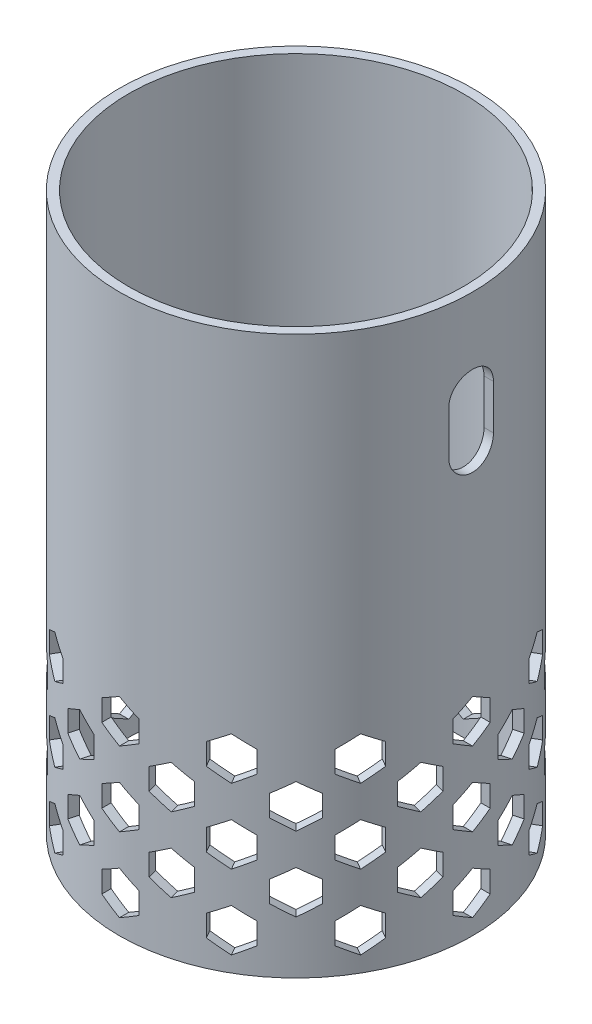
from build123d import *

# Parameters (mm, degrees)
SKETCH1_R               = 47.5
SKETCH1_R_2             = 45
BOSS_EXTRUDE1_DEPTH     = 150
CUT_EXTRUDE1_DEPTH      = 150
CUT_EXTRUDE2_DEPTH      = 48.5000001
CIRPATTERN1_COUNT       = 12
CUT_EXTRUDE3_DEPTH      = 130
CIRPATTERN2_COUNT       = 12
LPATTERN2_COUNT         = 2
LPATTERN2_PITCH         = 20
LPATTERN2_COPY_1_DEPTH  = 130
LPATTERN2_COPY_2_DEPTH  = 130
LPATTERN2_COPY_3_DEPTH  = 130
LPATTERN2_COPY_4_DEPTH  = 130
LPATTERN2_COPY_5_DEPTH  = 130
LPATTERN2_COPY_6_DEPTH  = 130
LPATTERN2_COPY_7_DEPTH  = 130
LPATTERN2_COPY_8_DEPTH  = 130
LPATTERN2_COPY_9_DEPTH  = 130
LPATTERN2_COPY_10_DEPTH = 130
LPATTERN2_COPY_11_DEPTH = 130
LPATTERN3_COUNT         = 3
LPATTERN3_PITCH         = 20
LPATTERN3_COPY_1_DEPTH  = 48.5000001
LPATTERN3_COPY_2_DEPTH  = 48.5000001
LPATTERN3_COPY_3_DEPTH  = 48.5000001
LPATTERN3_COPY_4_DEPTH  = 48.5000001
LPATTERN3_COPY_5_DEPTH  = 48.5000001
LPATTERN3_COPY_6_DEPTH  = 48.5000001
LPATTERN3_COPY_7_DEPTH  = 48.5000001
LPATTERN3_COPY_8_DEPTH  = 48.5000001
LPATTERN3_COPY_9_DEPTH  = 48.5000001
LPATTERN3_COPY_10_DEPTH = 48.5000001
LPATTERN3_COPY_11_DEPTH = 48.5000001
LPATTERN3_COPY_12_DEPTH = 48.5000001
LPATTERN3_COPY_13_DEPTH = 48.5000001
LPATTERN3_COPY_14_DEPTH = 48.5000001
LPATTERN3_COPY_15_DEPTH = 48.5000001
LPATTERN3_COPY_16_DEPTH = 48.5000001
LPATTERN3_COPY_17_DEPTH = 48.5000001
LPATTERN3_COPY_18_DEPTH = 48.5000001
LPATTERN3_COPY_19_DEPTH = 48.5000001
LPATTERN3_COPY_20_DEPTH = 48.5000001
LPATTERN3_COPY_21_DEPTH = 48.5000001
LPATTERN3_COPY_22_DEPTH = 48.5000001


with BuildPart() as part:
    # Sketch1 → Boss-Extrude1 (new body)
    with BuildSketch(Plane(origin=(0, 0, 0), x_dir=(1, 0, 0), z_dir=(0, 1, 0))):
        Circle(SKETCH1_R)
        Circle(SKETCH1_R_2, mode=Mode.SUBTRACT)
    extrude(amount=BOSS_EXTRUDE1_DEPTH)

    # Sketch2 → Cut-Extrude1 (cut)
    with BuildSketch(Plane(origin=(0, 0, 0), x_dir=(0, 0, -1), z_dir=(1, 0, 0))):
        with BuildLine():
            Line((6, 126), (6, 114))
            ThreePointArc((6, 114), (0, 108), (-6, 114))
            Line((-6, 114), (-6, 126))
            ThreePointArc((-6, 126), (0, 132), (6, 126))
        make_face()
    extrude(amount=CUT_EXTRUDE1_DEPTH, mode=Mode.SUBTRACT)

    # Sketch3 → Cut-Extrude2 (cut, symmetric)
    with BuildSketch(Plane(origin=(0, 0, 0), x_dir=(0, 0, -1), z_dir=(1, 0, 0))):
        Polygon((0, 4.226497308), (5, 7.113248654), (5, 12.886751346), (0, 15.773502692), (-5, 12.886751346), (-5, 7.113248654), align=None)
    cut_extrude2 = extrude(amount=CUT_EXTRUDE2_DEPTH, both=True, mode=Mode.SUBTRACT)

    # CirPattern1: Cut-Extrude2 ×12 about axis
    cirpattern1_axis = Axis((0, 0, 0), (0, 1, 0))
    for i in range(1, CIRPATTERN1_COUNT):
        add(cut_extrude2.rotate(cirpattern1_axis, i * 360 / CIRPATTERN1_COUNT), mode=Mode.SUBTRACT)

    # Sketch5 → Cut-Extrude3 (cut)
    with BuildSketch(Plane(origin=(0, 0, 0), x_dir=(0, 1, 0), z_dir=(-0.965925826, 0, 0.258819045))):
        Polygon((14.226497308, 0), (17.113248654, -5), (22.886751346, -5), (25.773502692, 0), (22.886751346, 5), (17.113248654, 5), align=None)
    cut_extrude3 = extrude(amount=-CUT_EXTRUDE3_DEPTH, mode=Mode.SUBTRACT)

    # CirPattern2: Cut-Extrude3 ×12 about axis
    cirpattern2_axis = Axis((0, 0, 0), (0, 1, 0))
    for i in range(1, CIRPATTERN2_COUNT):
        add(cut_extrude3.rotate(cirpattern2_axis, i * 360 / CIRPATTERN2_COUNT), mode=Mode.SUBTRACT)

    # LPattern2: Cut-Extrude3 ×2
    with Locations(*[(0, i * LPATTERN2_PITCH, 0) for i in range(1, LPATTERN2_COUNT)]):
        add(cut_extrude3, mode=Mode.SUBTRACT)

    # LPattern2 copy 1 sketch → LPattern2 copy 1 (cut)
    with BuildSketch(Plane(origin=(0, 20, 0), x_dir=(0, 1, 0), z_dir=(-0.707106781, 0, 0.707106781))):
        Polygon((14.226497308, 0), (17.113248654, -5), (22.886751346, -5), (25.773502692, 0), (22.886751346, 5), (17.113248654, 5), align=None)
    extrude(amount=-LPATTERN2_COPY_1_DEPTH, mode=Mode.SUBTRACT)

    # LPattern2 copy 2 sketch → LPattern2 copy 2 (cut)
    with BuildSketch(Plane(origin=(0, 20, 0), x_dir=(0, 1, 0), z_dir=(-0.258819045, 0, 0.965925826))):
        Polygon((14.226497308, 0), (17.113248654, -5), (22.886751346, -5), (25.773502692, 0), (22.886751346, 5), (17.113248654, 5), align=None)
    extrude(amount=-LPATTERN2_COPY_2_DEPTH, mode=Mode.SUBTRACT)

    # LPattern2 copy 3 sketch → LPattern2 copy 3 (cut)
    with BuildSketch(Plane(origin=(0, 20, 0), x_dir=(0, 1, 0), z_dir=(0.258819045, 0, 0.965925826))):
        Polygon((14.226497308, 0), (17.113248654, -5), (22.886751346, -5), (25.773502692, 0), (22.886751346, 5), (17.113248654, 5), align=None)
    extrude(amount=-LPATTERN2_COPY_3_DEPTH, mode=Mode.SUBTRACT)

    # LPattern2 copy 4 sketch → LPattern2 copy 4 (cut)
    with BuildSketch(Plane(origin=(0, 20, 0), x_dir=(0, 1, 0), z_dir=(0.707106781, 0, 0.707106781))):
        Polygon((14.226497308, 0), (17.113248654, -5), (22.886751346, -5), (25.773502692, 0), (22.886751346, 5), (17.113248654, 5), align=None)
    extrude(amount=-LPATTERN2_COPY_4_DEPTH, mode=Mode.SUBTRACT)

    # LPattern2 copy 5 sketch → LPattern2 copy 5 (cut)
    with BuildSketch(Plane(origin=(0, 20, 0), x_dir=(0, 1, 0), z_dir=(0.965925826, 0, 0.258819045))):
        Polygon((14.226497308, 0), (17.113248654, -5), (22.886751346, -5), (25.773502692, 0), (22.886751346, 5), (17.113248654, 5), align=None)
    extrude(amount=-LPATTERN2_COPY_5_DEPTH, mode=Mode.SUBTRACT)

    # LPattern2 copy 6 sketch → LPattern2 copy 6 (cut)
    with BuildSketch(Plane(origin=(0, 20, 0), x_dir=(0, 1, 0), z_dir=(0.965925826, 0, -0.258819045))):
        Polygon((14.226497308, 0), (17.113248654, -5), (22.886751346, -5), (25.773502692, 0), (22.886751346, 5), (17.113248654, 5), align=None)
    extrude(amount=-LPATTERN2_COPY_6_DEPTH, mode=Mode.SUBTRACT)

    # LPattern2 copy 7 sketch → LPattern2 copy 7 (cut)
    with BuildSketch(Plane(origin=(0, 20, 0), x_dir=(0, 1, 0), z_dir=(0.707106781, 0, -0.707106781))):
        Polygon((14.226497308, 0), (17.113248654, -5), (22.886751346, -5), (25.773502692, 0), (22.886751346, 5), (17.113248654, 5), align=None)
    extrude(amount=-LPATTERN2_COPY_7_DEPTH, mode=Mode.SUBTRACT)

    # LPattern2 copy 8 sketch → LPattern2 copy 8 (cut)
    with BuildSketch(Plane(origin=(0, 20, 0), x_dir=(0, 1, 0), z_dir=(0.258819045, 0, -0.965925826))):
        Polygon((14.226497308, 0), (17.113248654, -5), (22.886751346, -5), (25.773502692, 0), (22.886751346, 5), (17.113248654, 5), align=None)
    extrude(amount=-LPATTERN2_COPY_8_DEPTH, mode=Mode.SUBTRACT)

    # LPattern2 copy 9 sketch → LPattern2 copy 9 (cut)
    with BuildSketch(Plane(origin=(0, 20, 0), x_dir=(0, 1, 0), z_dir=(-0.258819045, 0, -0.965925826))):
        Polygon((14.226497308, 0), (17.113248654, -5), (22.886751346, -5), (25.773502692, 0), (22.886751346, 5), (17.113248654, 5), align=None)
    extrude(amount=-LPATTERN2_COPY_9_DEPTH, mode=Mode.SUBTRACT)

    # LPattern2 copy 10 sketch → LPattern2 copy 10 (cut)
    with BuildSketch(Plane(origin=(0, 20, 0), x_dir=(0, 1, 0), z_dir=(-0.707106781, 0, -0.707106781))):
        Polygon((14.226497308, 0), (17.113248654, -5), (22.886751346, -5), (25.773502692, 0), (22.886751346, 5), (17.113248654, 5), align=None)
    extrude(amount=-LPATTERN2_COPY_10_DEPTH, mode=Mode.SUBTRACT)

    # LPattern2 copy 11 sketch → LPattern2 copy 11 (cut)
    with BuildSketch(Plane(origin=(0, 20, 0), x_dir=(0, 1, 0), z_dir=(-0.965925826, 0, -0.258819045))):
        Polygon((14.226497308, 0), (17.113248654, -5), (22.886751346, -5), (25.773502692, 0), (22.886751346, 5), (17.113248654, 5), align=None)
    extrude(amount=-LPATTERN2_COPY_11_DEPTH, mode=Mode.SUBTRACT)

    # LPattern3: Cut-Extrude2 ×3
    with Locations(*[(0, i * LPATTERN3_PITCH, 0) for i in range(1, LPATTERN3_COUNT)]):
        add(cut_extrude2, mode=Mode.SUBTRACT)

    # LPattern3 copy 1 sketch → LPattern3 copy 1 (cut, symmetric)
    with BuildSketch(Plane(origin=(0, 20, 0), x_dir=(-0.5, 0, -0.866025404), z_dir=(0.866025404, 0, -0.5))):
        Polygon((0, 4.226497308), (5, 7.113248654), (5, 12.886751346), (0, 15.773502692), (-5, 12.886751346), (-5, 7.113248654), align=None)
    extrude(amount=LPATTERN3_COPY_1_DEPTH, both=True, mode=Mode.SUBTRACT)

    # LPattern3 copy 2 sketch → LPattern3 copy 2 (cut, symmetric)
    with BuildSketch(Plane(origin=(0, 40, 0), x_dir=(-0.5, 0, -0.866025404), z_dir=(0.866025404, 0, -0.5))):
        Polygon((0, 4.226497308), (5, 7.113248654), (5, 12.886751346), (0, 15.773502692), (-5, 12.886751346), (-5, 7.113248654), align=None)
    extrude(amount=LPATTERN3_COPY_2_DEPTH, both=True, mode=Mode.SUBTRACT)

    # LPattern3 copy 3 sketch → LPattern3 copy 3 (cut, symmetric)
    with BuildSketch(Plane(origin=(0, 20, 0), x_dir=(-0.866025404, 0, -0.5), z_dir=(0.5, 0, -0.866025404))):
        Polygon((0, 4.226497308), (5, 7.113248654), (5, 12.886751346), (0, 15.773502692), (-5, 12.886751346), (-5, 7.113248654), align=None)
    extrude(amount=LPATTERN3_COPY_3_DEPTH, both=True, mode=Mode.SUBTRACT)

    # LPattern3 copy 4 sketch → LPattern3 copy 4 (cut, symmetric)
    with BuildSketch(Plane(origin=(0, 40, 0), x_dir=(-0.866025404, 0, -0.5), z_dir=(0.5, 0, -0.866025404))):
        Polygon((0, 4.226497308), (5, 7.113248654), (5, 12.886751346), (0, 15.773502692), (-5, 12.886751346), (-5, 7.113248654), align=None)
    extrude(amount=LPATTERN3_COPY_4_DEPTH, both=True, mode=Mode.SUBTRACT)

    # LPattern3 copy 5 sketch → LPattern3 copy 5 (cut, symmetric)
    with BuildSketch(Plane(origin=(0, 20, 0), x_dir=(-1, 0, 0), z_dir=(0, 0, -1))):
        Polygon((0, 4.226497308), (5, 7.113248654), (5, 12.886751346), (0, 15.773502692), (-5, 12.886751346), (-5, 7.113248654), align=None)
    extrude(amount=LPATTERN3_COPY_5_DEPTH, both=True, mode=Mode.SUBTRACT)

    # LPattern3 copy 6 sketch → LPattern3 copy 6 (cut, symmetric)
    with BuildSketch(Plane(origin=(0, 40, 0), x_dir=(-1, 0, 0), z_dir=(0, 0, -1))):
        Polygon((0, 4.226497308), (5, 7.113248654), (5, 12.886751346), (0, 15.773502692), (-5, 12.886751346), (-5, 7.113248654), align=None)
    extrude(amount=LPATTERN3_COPY_6_DEPTH, both=True, mode=Mode.SUBTRACT)

    # LPattern3 copy 7 sketch → LPattern3 copy 7 (cut, symmetric)
    with BuildSketch(Plane(origin=(0, 20, 0), x_dir=(-0.866025404, 0, 0.5), z_dir=(-0.5, 0, -0.866025404))):
        Polygon((0, 4.226497308), (5, 7.113248654), (5, 12.886751346), (0, 15.773502692), (-5, 12.886751346), (-5, 7.113248654), align=None)
    extrude(amount=LPATTERN3_COPY_7_DEPTH, both=True, mode=Mode.SUBTRACT)

    # LPattern3 copy 8 sketch → LPattern3 copy 8 (cut, symmetric)
    with BuildSketch(Plane(origin=(0, 40, 0), x_dir=(-0.866025404, 0, 0.5), z_dir=(-0.5, 0, -0.866025404))):
        Polygon((0, 4.226497308), (5, 7.113248654), (5, 12.886751346), (0, 15.773502692), (-5, 12.886751346), (-5, 7.113248654), align=None)
    extrude(amount=LPATTERN3_COPY_8_DEPTH, both=True, mode=Mode.SUBTRACT)

    # LPattern3 copy 9 sketch → LPattern3 copy 9 (cut, symmetric)
    with BuildSketch(Plane(origin=(0, 20, 0), x_dir=(-0.5, 0, 0.866025404), z_dir=(-0.866025404, 0, -0.5))):
        Polygon((0, 4.226497308), (5, 7.113248654), (5, 12.886751346), (0, 15.773502692), (-5, 12.886751346), (-5, 7.113248654), align=None)
    extrude(amount=LPATTERN3_COPY_9_DEPTH, both=True, mode=Mode.SUBTRACT)

    # LPattern3 copy 10 sketch → LPattern3 copy 10 (cut, symmetric)
    with BuildSketch(Plane(origin=(0, 40, 0), x_dir=(-0.5, 0, 0.866025404), z_dir=(-0.866025404, 0, -0.5))):
        Polygon((0, 4.226497308), (5, 7.113248654), (5, 12.886751346), (0, 15.773502692), (-5, 12.886751346), (-5, 7.113248654), align=None)
    extrude(amount=LPATTERN3_COPY_10_DEPTH, both=True, mode=Mode.SUBTRACT)

    # LPattern3 copy 11 sketch → LPattern3 copy 11 (cut, symmetric)
    with BuildSketch(Plane(origin=(0, 20, 0), x_dir=(0, 0, 1), z_dir=(-1, 0, 0))):
        Polygon((0, 4.226497308), (5, 7.113248654), (5, 12.886751346), (0, 15.773502692), (-5, 12.886751346), (-5, 7.113248654), align=None)
    extrude(amount=LPATTERN3_COPY_11_DEPTH, both=True, mode=Mode.SUBTRACT)

    # LPattern3 copy 12 sketch → LPattern3 copy 12 (cut, symmetric)
    with BuildSketch(Plane(origin=(0, 40, 0), x_dir=(0, 0, 1), z_dir=(-1, 0, 0))):
        Polygon((0, 4.226497308), (5, 7.113248654), (5, 12.886751346), (0, 15.773502692), (-5, 12.886751346), (-5, 7.113248654), align=None)
    extrude(amount=LPATTERN3_COPY_12_DEPTH, both=True, mode=Mode.SUBTRACT)

    # LPattern3 copy 13 sketch → LPattern3 copy 13 (cut, symmetric)
    with BuildSketch(Plane(origin=(0, 20, 0), x_dir=(0.5, 0, 0.866025404), z_dir=(-0.866025404, 0, 0.5))):
        Polygon((0, 4.226497308), (5, 7.113248654), (5, 12.886751346), (0, 15.773502692), (-5, 12.886751346), (-5, 7.113248654), align=None)
    extrude(amount=LPATTERN3_COPY_13_DEPTH, both=True, mode=Mode.SUBTRACT)

    # LPattern3 copy 14 sketch → LPattern3 copy 14 (cut, symmetric)
    with BuildSketch(Plane(origin=(0, 40, 0), x_dir=(0.5, 0, 0.866025404), z_dir=(-0.866025404, 0, 0.5))):
        Polygon((0, 4.226497308), (5, 7.113248654), (5, 12.886751346), (0, 15.773502692), (-5, 12.886751346), (-5, 7.113248654), align=None)
    extrude(amount=LPATTERN3_COPY_14_DEPTH, both=True, mode=Mode.SUBTRACT)

    # LPattern3 copy 15 sketch → LPattern3 copy 15 (cut, symmetric)
    with BuildSketch(Plane(origin=(0, 20, 0), x_dir=(0.866025404, 0, 0.5), z_dir=(-0.5, 0, 0.866025404))):
        Polygon((0, 4.226497308), (5, 7.113248654), (5, 12.886751346), (0, 15.773502692), (-5, 12.886751346), (-5, 7.113248654), align=None)
    extrude(amount=LPATTERN3_COPY_15_DEPTH, both=True, mode=Mode.SUBTRACT)

    # LPattern3 copy 16 sketch → LPattern3 copy 16 (cut, symmetric)
    with BuildSketch(Plane(origin=(0, 40, 0), x_dir=(0.866025404, 0, 0.5), z_dir=(-0.5, 0, 0.866025404))):
        Polygon((0, 4.226497308), (5, 7.113248654), (5, 12.886751346), (0, 15.773502692), (-5, 12.886751346), (-5, 7.113248654), align=None)
    extrude(amount=LPATTERN3_COPY_16_DEPTH, both=True, mode=Mode.SUBTRACT)

    # LPattern3 copy 17 sketch → LPattern3 copy 17 (cut, symmetric)
    with BuildSketch(Plane(origin=(0, 20, 0), x_dir=(1, 0, 0), z_dir=(0, 0, 1))):
        Polygon((0, 4.226497308), (5, 7.113248654), (5, 12.886751346), (0, 15.773502692), (-5, 12.886751346), (-5, 7.113248654), align=None)
    extrude(amount=LPATTERN3_COPY_17_DEPTH, both=True, mode=Mode.SUBTRACT)

    # LPattern3 copy 18 sketch → LPattern3 copy 18 (cut, symmetric)
    with BuildSketch(Plane(origin=(0, 40, 0), x_dir=(1, 0, 0), z_dir=(0, 0, 1))):
        Polygon((0, 4.226497308), (5, 7.113248654), (5, 12.886751346), (0, 15.773502692), (-5, 12.886751346), (-5, 7.113248654), align=None)
    extrude(amount=LPATTERN3_COPY_18_DEPTH, both=True, mode=Mode.SUBTRACT)

    # LPattern3 copy 19 sketch → LPattern3 copy 19 (cut, symmetric)
    with BuildSketch(Plane(origin=(0, 20, 0), x_dir=(0.866025404, 0, -0.5), z_dir=(0.5, 0, 0.866025404))):
        Polygon((0, 4.226497308), (5, 7.113248654), (5, 12.886751346), (0, 15.773502692), (-5, 12.886751346), (-5, 7.113248654), align=None)
    extrude(amount=LPATTERN3_COPY_19_DEPTH, both=True, mode=Mode.SUBTRACT)

    # LPattern3 copy 20 sketch → LPattern3 copy 20 (cut, symmetric)
    with BuildSketch(Plane(origin=(0, 40, 0), x_dir=(0.866025404, 0, -0.5), z_dir=(0.5, 0, 0.866025404))):
        Polygon((0, 4.226497308), (5, 7.113248654), (5, 12.886751346), (0, 15.773502692), (-5, 12.886751346), (-5, 7.113248654), align=None)
    extrude(amount=LPATTERN3_COPY_20_DEPTH, both=True, mode=Mode.SUBTRACT)

    # LPattern3 copy 21 sketch → LPattern3 copy 21 (cut, symmetric)
    with BuildSketch(Plane(origin=(0, 20, 0), x_dir=(0.5, 0, -0.866025404), z_dir=(0.866025404, 0, 0.5))):
        Polygon((0, 4.226497308), (5, 7.113248654), (5, 12.886751346), (0, 15.773502692), (-5, 12.886751346), (-5, 7.113248654), align=None)
    extrude(amount=LPATTERN3_COPY_21_DEPTH, both=True, mode=Mode.SUBTRACT)

    # LPattern3 copy 22 sketch → LPattern3 copy 22 (cut, symmetric)
    with BuildSketch(Plane(origin=(0, 40, 0), x_dir=(0.5, 0, -0.866025404), z_dir=(0.866025404, 0, 0.5))):
        Polygon((0, 4.226497308), (5, 7.113248654), (5, 12.886751346), (0, 15.773502692), (-5, 12.886751346), (-5, 7.113248654), align=None)
    extrude(amount=LPATTERN3_COPY_22_DEPTH, both=True, mode=Mode.SUBTRACT)


solid = part.part
